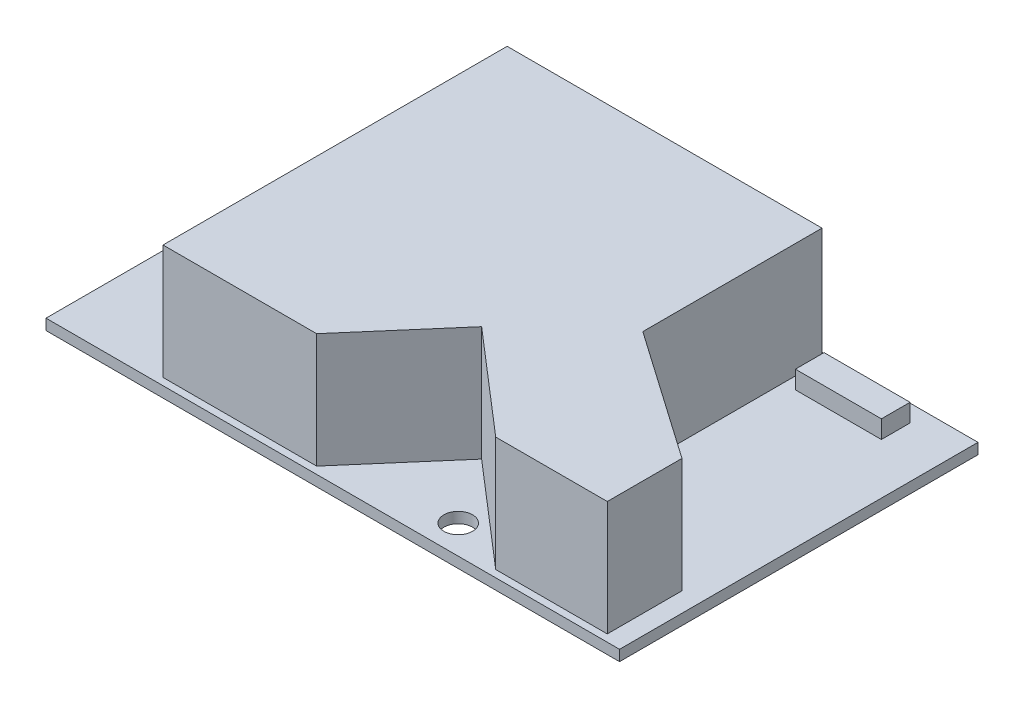
from build123d import *

# Parameters (mm, degrees)
SKETCH2_W           = 80
SKETCH2_H           = 50
SKETCH2_R           = 2
BOSS_EXTRUDE1_DEPTH = 1.5
BOSS_EXTRUDE2_DEPTH = 17.5
SKETCH2_5_W         = 12
SKETCH2_5_H         = 4
BOSS_EXTRUDE3_DEPTH = 4


with BuildPart() as part:
    # Sketch2 → Boss-Extrude1 (new body)
    with BuildSketch(Plane(origin=(0, 0, 0), x_dir=(1, 0, 0), z_dir=(0, 1, 0))):
        with Locations((40, -25)):
            Rectangle(SKETCH2_W, SKETCH2_H)
        with Locations((53.5, -46)):
            Circle(SKETCH2_R, mode=Mode.SUBTRACT)
    extrude(amount=BOSS_EXTRUDE1_DEPTH)

    # Sketch2_3 → Boss-Extrude2 (add)
    with BuildSketch(Plane(origin=(0, 0, 0), x_dir=(1, 0, 0), z_dir=(0, 1, 0))):
        Polygon((47.407334239, -36.646178921), (61.72925499, -49), (77.292723547, -49), (77.292723547, -38.583095808), (59.246513421, -26), (59.246513421, -1), (15.322098265, -1), (15.322098265, -49), (36.751159142, -49), align=None)
    extrude(amount=BOSS_EXTRUDE2_DEPTH)

    # Sketch2_5 → Boss-Extrude3 (add)
    with BuildSketch(Plane(origin=(0, 0, 0), x_dir=(1, 0, 0), z_dir=(0, 1, 0))):
        with Locations((66.923917494, -4.397775479)):
            Rectangle(SKETCH2_5_W, SKETCH2_5_H)
    extrude(amount=BOSS_EXTRUDE3_DEPTH)


solid = part.part
